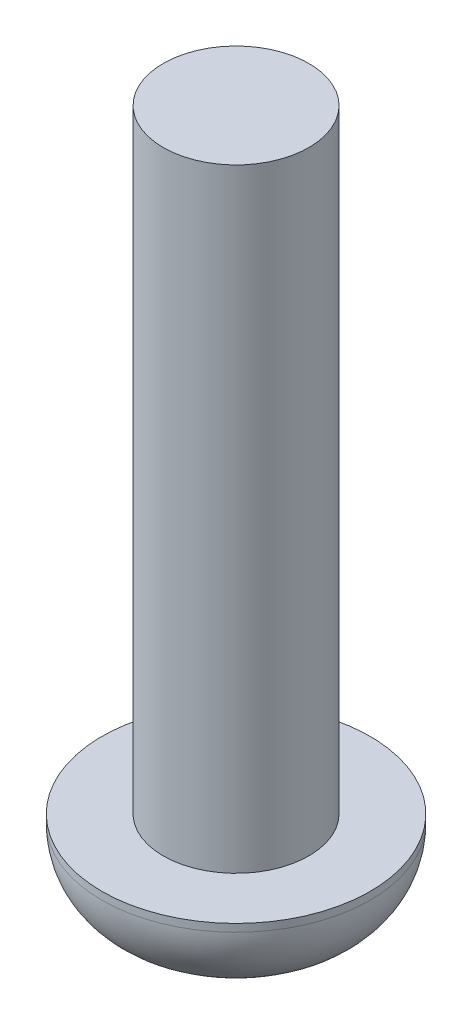
from build123d import *

# Parameters (mm, degrees)
SKETCH1_R           = 3.5
BOSS_EXTRUDE1_DEPTH = 2.2
SKETCH2_R           = 1.9
BOSS_EXTRUDE2_DEPTH = 16
FILLET1_R           = 2


with BuildPart() as part:
    # Sketch1 → Boss-Extrude1 (new body)
    with BuildSketch(Plane(origin=(0, 0, 0), x_dir=(1, 0, 0), z_dir=(0, 1, 0))):
        Circle(SKETCH1_R)
    extrude(amount=BOSS_EXTRUDE1_DEPTH)

    # Sketch2 → Boss-Extrude2 (add)
    with BuildSketch(Plane(origin=(0, 2.2, 0), x_dir=(1, 0, 0), z_dir=(0, 1, 0))):
        Circle(SKETCH2_R)
    extrude(amount=BOSS_EXTRUDE2_DEPTH)

    # Fillet1
    fillet1_edges = [part.edges().sort_by_distance(p)[0] for p in [
        (-3.5, 0, 0),
    ]]
    fillet(fillet1_edges, radius=FILLET1_R)


solid = part.part
